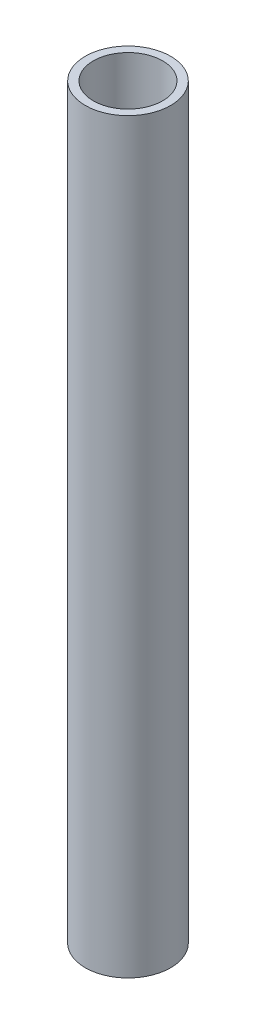
from build123d import *

# Parameters (mm, degrees)
CROQUIS1_R              = 8
CROQUIS1_R_2            = 6.5
SALIENTE_EXTRUIR1_DEPTH = 140


with BuildPart() as part:
    # Croquis1 → Saliente-Extruir1 (new body)
    with BuildSketch(Plane(origin=(0, 0, 0), x_dir=(1, 0, 0), z_dir=(0, 1, 0))):
        Circle(CROQUIS1_R)
        Circle(CROQUIS1_R_2, mode=Mode.SUBTRACT)
    extrude(amount=SALIENTE_EXTRUIR1_DEPTH)


solid = part.part
